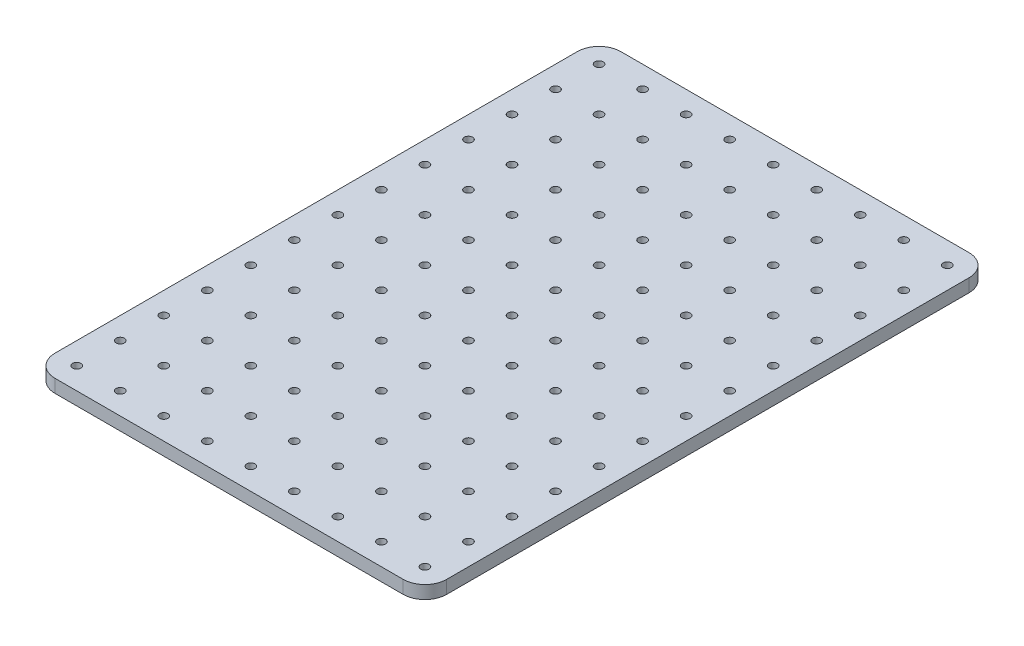
from build123d import *

# Parameters (mm, degrees)
SKETCH1_W           = 90
SKETCH1_H           = 130
BOSS_EXTRUDE1_DEPTH = 3
SKETCH2_R           = 0.95
CUT_EXTRUDE1_DEPTH  = 4
FILLET1_R           = 5


with BuildPart() as part:
    # Sketch1 → Boss-Extrude1 (new body)
    with BuildSketch(Plane(origin=(0, 0, 0), x_dir=(1, 0, 0), z_dir=(0, 1, 0))):
        Rectangle(SKETCH1_W, SKETCH1_H)
    extrude(amount=BOSS_EXTRUDE1_DEPTH)

    # Sketch2 → Cut-Extrude1 (cut, through all)
    with BuildSketch(Plane(origin=(0, 3, 0), x_dir=(1, 0, 0), z_dir=(0, 1, 0))):
        with Locations((-40, 60)):
            Circle(SKETCH2_R)
        with Locations((-30, 60)):
            Circle(SKETCH2_R)
        with Locations((-20, 60)):
            Circle(SKETCH2_R)
        with Locations((-10, 60)):
            Circle(SKETCH2_R)
        with Locations((0, 60)):
            Circle(SKETCH2_R)
        with Locations((10, 60)):
            Circle(SKETCH2_R)
        with Locations((20, 60)):
            Circle(SKETCH2_R)
        with Locations((-40, -40)):
            Circle(SKETCH2_R)
        with Locations((-40, -20)):
            Circle(SKETCH2_R)
        with Locations((-30, -20)):
            Circle(SKETCH2_R)
        with Locations((-30, 50)):
            Circle(SKETCH2_R)
        with Locations((-20, 50)):
            Circle(SKETCH2_R)
        with Locations((-10, 50)):
            Circle(SKETCH2_R)
        with Locations((0, 50)):
            Circle(SKETCH2_R)
        with Locations((10, 50)):
            Circle(SKETCH2_R)
        with Locations((20, 50)):
            Circle(SKETCH2_R)
        with Locations((-30, -40)):
            Circle(SKETCH2_R)
        with Locations((-20, -20)):
            Circle(SKETCH2_R)
        with Locations((-10, -20)):
            Circle(SKETCH2_R)
        with Locations((-30, 40)):
            Circle(SKETCH2_R)
        with Locations((-20, 40)):
            Circle(SKETCH2_R)
        with Locations((-10, 40)):
            Circle(SKETCH2_R)
        with Locations((0, 40)):
            Circle(SKETCH2_R)
        with Locations((10, 40)):
            Circle(SKETCH2_R)
        with Locations((20, 40)):
            Circle(SKETCH2_R)
        with Locations((-20, -40)):
            Circle(SKETCH2_R)
        with Locations((0, -20)):
            Circle(SKETCH2_R)
        with Locations((10, -20)):
            Circle(SKETCH2_R)
        with Locations((-30, 30)):
            Circle(SKETCH2_R)
        with Locations((-20, 30)):
            Circle(SKETCH2_R)
        with Locations((-10, 30)):
            Circle(SKETCH2_R)
        with Locations((0, 30)):
            Circle(SKETCH2_R)
        with Locations((10, 30)):
            Circle(SKETCH2_R)
        with Locations((20, 30)):
            Circle(SKETCH2_R)
        with Locations((-10, -40)):
            Circle(SKETCH2_R)
        with Locations((20, -20)):
            Circle(SKETCH2_R)
        with Locations((0, -40)):
            Circle(SKETCH2_R)
        with Locations((-40, 50)):
            Circle(SKETCH2_R)
        with Locations((-40, 40)):
            Circle(SKETCH2_R)
        with Locations((-40, 30)):
            Circle(SKETCH2_R)
        with Locations((-40, 20)):
            Circle(SKETCH2_R)
        with Locations((-30, 20)):
            Circle(SKETCH2_R)
        with Locations((-20, 20)):
            Circle(SKETCH2_R)
        with Locations((-10, 20)):
            Circle(SKETCH2_R)
        with Locations((0, 20)):
            Circle(SKETCH2_R)
        with Locations((10, 20)):
            Circle(SKETCH2_R)
        with Locations((20, 20)):
            Circle(SKETCH2_R)
        with Locations((10, -40)):
            Circle(SKETCH2_R)
        with Locations((-40, -30)):
            Circle(SKETCH2_R)
        with Locations((-30, -30)):
            Circle(SKETCH2_R)
        with Locations((-20, -30)):
            Circle(SKETCH2_R)
        with Locations((-10, -30)):
            Circle(SKETCH2_R)
        with Locations((0, -30)):
            Circle(SKETCH2_R)
        with Locations((10, -30)):
            Circle(SKETCH2_R)
        with Locations((20, -30)):
            Circle(SKETCH2_R)
        with Locations((20, -40)):
            Circle(SKETCH2_R)
        with Locations((-40, -50)):
            Circle(SKETCH2_R)
        with Locations((-30, -50)):
            Circle(SKETCH2_R)
        with Locations((-20, -50)):
            Circle(SKETCH2_R)
        with Locations((-10, -50)):
            Circle(SKETCH2_R)
        with Locations((0, -50)):
            Circle(SKETCH2_R)
        with Locations((10, -50)):
            Circle(SKETCH2_R)
        with Locations((20, -50)):
            Circle(SKETCH2_R)
        with Locations((-40, -60)):
            Circle(SKETCH2_R)
        with Locations((-30, -60)):
            Circle(SKETCH2_R)
        with Locations((-20, -60)):
            Circle(SKETCH2_R)
        with Locations((-10, -60)):
            Circle(SKETCH2_R)
        with Locations((0, -60)):
            Circle(SKETCH2_R)
        with Locations((10, -60)):
            Circle(SKETCH2_R)
        with Locations((20, -60)):
            Circle(SKETCH2_R)
        with Locations((30, 60)):
            Circle(SKETCH2_R)
        with Locations((30, 50)):
            Circle(SKETCH2_R)
        with Locations((30, 40)):
            Circle(SKETCH2_R)
        with Locations((30, 30)):
            Circle(SKETCH2_R)
        with Locations((30, 20)):
            Circle(SKETCH2_R)
        with Locations((30, 10)):
            Circle(SKETCH2_R)
        with Locations((30, 0)):
            Circle(SKETCH2_R)
        with Locations((30, -10)):
            Circle(SKETCH2_R)
        with Locations((30, -20)):
            Circle(SKETCH2_R)
        with Locations((30, -30)):
            Circle(SKETCH2_R)
        with Locations((30, -40)):
            Circle(SKETCH2_R)
        with Locations((30, -50)):
            Circle(SKETCH2_R)
        with Locations((30, -60)):
            Circle(SKETCH2_R)
        with Locations((40, 60)):
            Circle(SKETCH2_R)
        with Locations((40, 50)):
            Circle(SKETCH2_R)
        with Locations((40, 40)):
            Circle(SKETCH2_R)
        with Locations((-40, 10)):
            Circle(SKETCH2_R)
        with Locations((-30, 10)):
            Circle(SKETCH2_R)
        with Locations((-20, 10)):
            Circle(SKETCH2_R)
        with Locations((-10, 10)):
            Circle(SKETCH2_R)
        with Locations((0, 10)):
            Circle(SKETCH2_R)
        with Locations((40, 30)):
            Circle(SKETCH2_R)
        with Locations((40, 20)):
            Circle(SKETCH2_R)
        with Locations((40, 10)):
            Circle(SKETCH2_R)
        with Locations((40, 0)):
            Circle(SKETCH2_R)
        with Locations((10, 10)):
            Circle(SKETCH2_R)
        with Locations((20, 10)):
            Circle(SKETCH2_R)
        with Locations((40, -10)):
            Circle(SKETCH2_R)
        with Locations((40, -20)):
            Circle(SKETCH2_R)
        with Locations((40, -30)):
            Circle(SKETCH2_R)
        with Locations((40, -40)):
            Circle(SKETCH2_R)
        with Locations((40, -50)):
            Circle(SKETCH2_R)
        with Locations((40, -60)):
            Circle(SKETCH2_R)
        with Locations((-40, -70)):
            Circle(SKETCH2_R)
        with Locations((-30, -70)):
            Circle(SKETCH2_R)
        with Locations((-20, -70)):
            Circle(SKETCH2_R)
        with Locations((-10, -70)):
            Circle(SKETCH2_R)
        with Locations((0, -70)):
            Circle(SKETCH2_R)
        with Locations((-40, 0)):
            Circle(SKETCH2_R)
        with Locations((-30, 0)):
            Circle(SKETCH2_R)
        with Locations((-20, 0)):
            Circle(SKETCH2_R)
        with Locations((-10, 0)):
            Circle(SKETCH2_R)
        Circle(SKETCH2_R)
        with Locations((10, 0)):
            Circle(SKETCH2_R)
        with Locations((20, 0)):
            Circle(SKETCH2_R)
        with Locations((10, -70)):
            Circle(SKETCH2_R)
        with Locations((20, -70)):
            Circle(SKETCH2_R)
        with Locations((30, -70)):
            Circle(SKETCH2_R)
        with Locations((40, -70)):
            Circle(SKETCH2_R)
        with Locations((-40, -80)):
            Circle(SKETCH2_R)
        with Locations((-30, -80)):
            Circle(SKETCH2_R)
        with Locations((-20, -80)):
            Circle(SKETCH2_R)
        with Locations((-10, -80)):
            Circle(SKETCH2_R)
        with Locations((0, -80)):
            Circle(SKETCH2_R)
        with Locations((10, -80)):
            Circle(SKETCH2_R)
        with Locations((20, -80)):
            Circle(SKETCH2_R)
        with Locations((-40, -10)):
            Circle(SKETCH2_R)
        with Locations((-30, -10)):
            Circle(SKETCH2_R)
        with Locations((-20, -10)):
            Circle(SKETCH2_R)
        with Locations((-10, -10)):
            Circle(SKETCH2_R)
        with Locations((0, -10)):
            Circle(SKETCH2_R)
        with Locations((10, -10)):
            Circle(SKETCH2_R)
        with Locations((20, -10)):
            Circle(SKETCH2_R)
        with Locations((30, -80)):
            Circle(SKETCH2_R)
        with Locations((40, -80)):
            Circle(SKETCH2_R)
        with Locations((-40, -90)):
            Circle(SKETCH2_R)
        with Locations((-30, -90)):
            Circle(SKETCH2_R)
        with Locations((-20, -90)):
            Circle(SKETCH2_R)
        with Locations((-10, -90)):
            Circle(SKETCH2_R)
        with Locations((0, -90)):
            Circle(SKETCH2_R)
        with Locations((10, -90)):
            Circle(SKETCH2_R)
        with Locations((20, -90)):
            Circle(SKETCH2_R)
        with Locations((30, -90)):
            Circle(SKETCH2_R)
        with Locations((40, -90)):
            Circle(SKETCH2_R)
        with Locations((-40, -100)):
            Circle(SKETCH2_R)
        with Locations((-30, -100)):
            Circle(SKETCH2_R)
        with Locations((-20, -100)):
            Circle(SKETCH2_R)
        with Locations((-10, -100)):
            Circle(SKETCH2_R)
        with Locations((0, -100)):
            Circle(SKETCH2_R)
        with Locations((10, -100)):
            Circle(SKETCH2_R)
        with Locations((20, -100)):
            Circle(SKETCH2_R)
        with Locations((30, -100)):
            Circle(SKETCH2_R)
        with Locations((40, -100)):
            Circle(SKETCH2_R)
        with Locations((-40, -110)):
            Circle(SKETCH2_R)
        with Locations((-30, -110)):
            Circle(SKETCH2_R)
        with Locations((-20, -110)):
            Circle(SKETCH2_R)
        with Locations((-10, -110)):
            Circle(SKETCH2_R)
        with Locations((0, -110)):
            Circle(SKETCH2_R)
        with Locations((10, -110)):
            Circle(SKETCH2_R)
        with Locations((20, -110)):
            Circle(SKETCH2_R)
        with Locations((30, -110)):
            Circle(SKETCH2_R)
        with Locations((40, -110)):
            Circle(SKETCH2_R)
        with Locations((-40, -120)):
            Circle(SKETCH2_R)
        with Locations((-30, -120)):
            Circle(SKETCH2_R)
        with Locations((-20, -120)):
            Circle(SKETCH2_R)
        with Locations((-10, -120)):
            Circle(SKETCH2_R)
        with Locations((0, -120)):
            Circle(SKETCH2_R)
        with Locations((10, -120)):
            Circle(SKETCH2_R)
        with Locations((20, -120)):
            Circle(SKETCH2_R)
        with Locations((30, -120)):
            Circle(SKETCH2_R)
        with Locations((40, -120)):
            Circle(SKETCH2_R)
        with Locations((-40, -130)):
            Circle(SKETCH2_R)
        with Locations((-30, -130)):
            Circle(SKETCH2_R)
        with Locations((-20, -130)):
            Circle(SKETCH2_R)
        with Locations((-10, -130)):
            Circle(SKETCH2_R)
        with Locations((0, -130)):
            Circle(SKETCH2_R)
        with Locations((10, -130)):
            Circle(SKETCH2_R)
        with Locations((20, -130)):
            Circle(SKETCH2_R)
        with Locations((30, -130)):
            Circle(SKETCH2_R)
        with Locations((40, -130)):
            Circle(SKETCH2_R)
    extrude(amount=-CUT_EXTRUDE1_DEPTH, mode=Mode.SUBTRACT)

    # Fillet1
    fillet1_edges = [part.edges().sort_by_distance(p)[0] for p in [
        (45, 1.5, 65),
        (-45, 1.5, 65),
        (-45, 1.5, -65),
        (45, 1.5, -65),
    ]]
    fillet(fillet1_edges, radius=FILLET1_R)


solid = part.part
